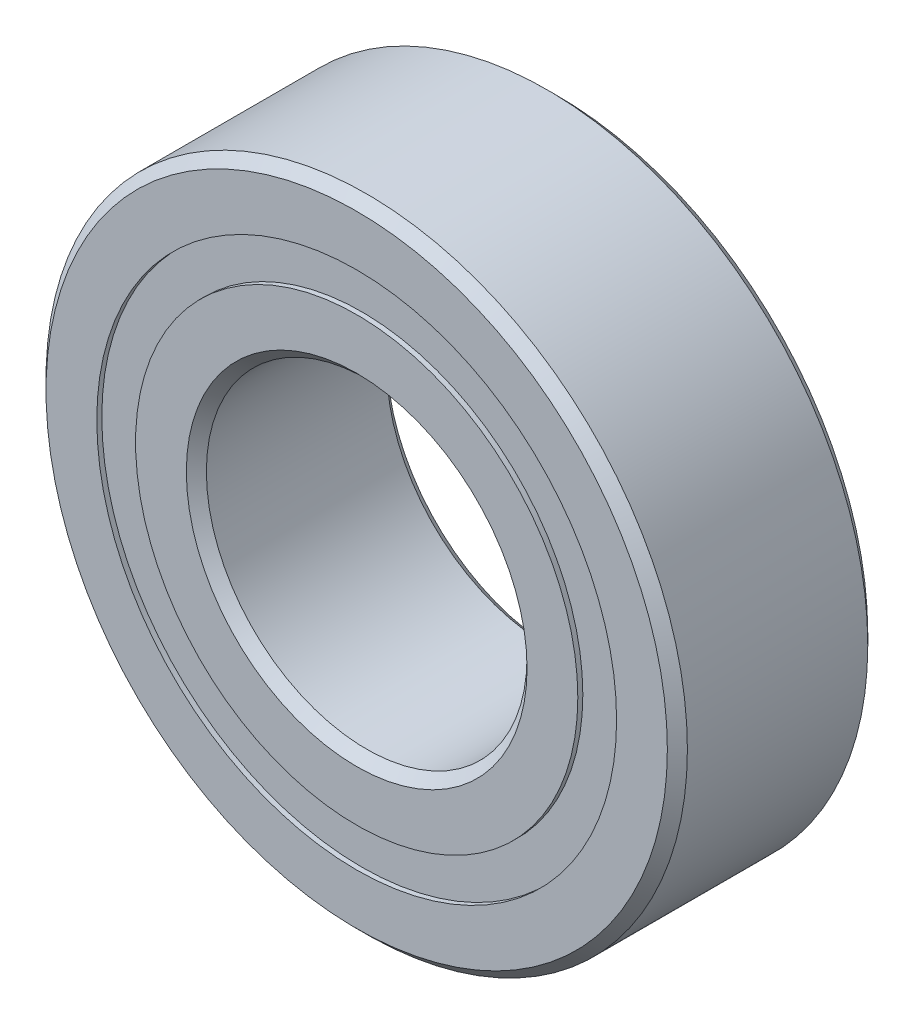
from build123d import *

# Parameters (mm, degrees)
CIRPATTERN1_COUNT = 12
SKETCH5_W         = 1.163242561
SKETCH5_H         = 0.967032968


with BuildPart() as part:
    # Sketch1 → Revolve1 (revolve)
    with BuildSketch(Plane(origin=(0, 0, 0), x_dir=(0, 0, -1), z_dir=(1, 0, 0))):
        with BuildLine():
            Line((2.25, 8), (-2.25, 8))
            Line((-2.25, 8), (-2.5, 7.75))
            Line((-2.5, 7.75), (-2.5, 6.483516484))
            Line((-2.5, 6.483516484), (-1.111111111, 6.483516484))
            ThreePointArc((-1.111111111, 6.483516484), (0, 7.211757439), (1.111111111, 6.483516484))
            Line((1.111111111, 6.483516484), (2.5, 6.483516484))
            Line((2.5, 6.483516484), (2.5, 7.75))
            Line((2.5, 7.75), (2.25, 8))
        make_face()
    revolve(axis=Axis((0, 0, 2.5), (0, 0, -1)))


with BuildPart() as body_2:
    # Sketch3 → Revolve3 (revolve)
    with BuildSketch(Plane(origin=(0, 0, 0), x_dir=(0, 0, -1), z_dir=(1, 0, 0))):
        with BuildLine():
            Line((-2.5, 5.516483516), (-1.111111111, 5.516483516))
            ThreePointArc((-1.111111111, 5.516483516), (0, 4.788242561), (1.111111111, 5.516483516))
            Line((1.111111111, 5.516483516), (2.5, 5.516483516))
            Line((2.5, 5.516483516), (2.5, 4.25))
            Line((2.5, 4.25), (2.25, 4))
            Line((2.25, 4), (-2.25, 4))
            Line((-2.25, 4), (-2.5, 4.25))
            Line((-2.5, 4.25), (-2.5, 5.516483516))
        make_face()
    revolve(axis=Axis((0, 0, 2.5), (0, 0, -1)))


with BuildPart() as body_3:
    # Sketch4 → Revolve4 (revolve)
    with BuildSketch(Plane(origin=(0, 0, 0), x_dir=(0, 0, -1), z_dir=(1, 0, 0))):
        with BuildLine():
            Line((-1.211757439, 6), (1.211757439, 6))
            ThreePointArc((1.211757439, 6), (0, 7.211757439), (-1.211757439, 6))
        make_face()
    revolve(axis=Axis((0, 6, 1.211757439), (0, 0, -1)))


with BuildPart() as cirpattern1_1:
    # CirPattern1: pattern copy
    add(body_3.part.rotate(Axis((0, 0, -2.5), (0, 0, 1)), 1 * 360 / CIRPATTERN1_COUNT))


with BuildPart() as cirpattern1_2:
    # CirPattern1: pattern copy
    add(body_3.part.rotate(Axis((0, 0, -2.5), (0, 0, 1)), 2 * 360 / CIRPATTERN1_COUNT))


with BuildPart() as cirpattern1_3:
    # CirPattern1: pattern copy
    add(body_3.part.rotate(Axis((0, 0, -2.5), (0, 0, 1)), 3 * 360 / CIRPATTERN1_COUNT))


with BuildPart() as cirpattern1_4:
    # CirPattern1: pattern copy
    add(body_3.part.rotate(Axis((0, 0, -2.5), (0, 0, 1)), 4 * 360 / CIRPATTERN1_COUNT))


with BuildPart() as cirpattern1_5:
    # CirPattern1: pattern copy
    add(body_3.part.rotate(Axis((0, 0, -2.5), (0, 0, 1)), 5 * 360 / CIRPATTERN1_COUNT))


with BuildPart() as cirpattern1_6:
    # CirPattern1: pattern copy
    add(body_3.part.rotate(Axis((0, 0, -2.5), (0, 0, 1)), 6 * 360 / CIRPATTERN1_COUNT))


with BuildPart() as cirpattern1_7:
    # CirPattern1: pattern copy
    add(body_3.part.rotate(Axis((0, 0, -2.5), (0, 0, 1)), 7 * 360 / CIRPATTERN1_COUNT))


with BuildPart() as cirpattern1_8:
    # CirPattern1: pattern copy
    add(body_3.part.rotate(Axis((0, 0, -2.5), (0, 0, 1)), 8 * 360 / CIRPATTERN1_COUNT))


with BuildPart() as cirpattern1_9:
    # CirPattern1: pattern copy
    add(body_3.part.rotate(Axis((0, 0, -2.5), (0, 0, 1)), 9 * 360 / CIRPATTERN1_COUNT))


with BuildPart() as cirpattern1_10:
    # CirPattern1: pattern copy
    add(body_3.part.rotate(Axis((0, 0, -2.5), (0, 0, 1)), 10 * 360 / CIRPATTERN1_COUNT))


with BuildPart() as cirpattern1_11:
    # CirPattern1: pattern copy
    add(body_3.part.rotate(Axis((0, 0, -2.5), (0, 0, 1)), 11 * 360 / CIRPATTERN1_COUNT))


with BuildPart() as body_15:
    # Sketch5 → Revolve5 (revolve)
    with BuildSketch(Plane(origin=(0, 0, 0), x_dir=(0, 0, -1), z_dir=(1, 0, 0))):
        with Locations((-1.79337872, 6)):
            Rectangle(SKETCH5_W, SKETCH5_H)
        with Locations((1.79337872, 6)):
            Rectangle(SKETCH5_W, SKETCH5_H)
    revolve(axis=Axis((0, 0, 2.5), (0, 0, -1)))


solid = Compound([part.part, body_2.part, body_3.part, cirpattern1_1.part, cirpattern1_2.part, cirpattern1_3.part, cirpattern1_4.part, cirpattern1_5.part, cirpattern1_6.part, cirpattern1_7.part, cirpattern1_8.part, cirpattern1_9.part, cirpattern1_10.part, cirpattern1_11.part, body_15.part])
